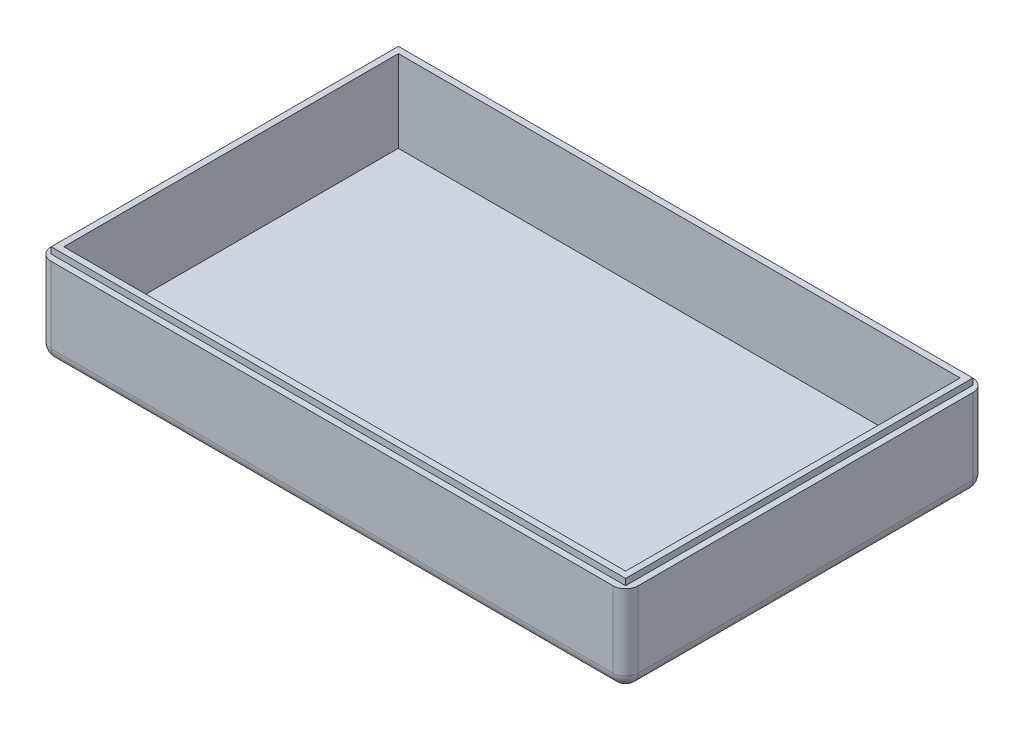
from build123d import *

# Parameters (mm, degrees)
SKETCH1_W           = 93
SKETCH1_H           = 57
BOSS_EXTRUDE1_DEPTH = 14
SHELL1_T            = -2
SKETCH2_W           = 91
SKETCH2_H           = 55
SKETCH2_W_2         = 89
SKETCH2_H_2         = 53
BOSS_EXTRUDE2_DEPTH = 1
FILLET2_R           = 2


with BuildPart() as part:
    # Sketch1 → Boss-Extrude1 (new body)
    with BuildSketch(Plane(origin=(0, 0, 0), x_dir=(1, 0, 0), z_dir=(0, 1, 0))):
        Rectangle(SKETCH1_W, SKETCH1_H)
    extrude(amount=BOSS_EXTRUDE1_DEPTH)

    # Shell1
    shell1_openings = [part.faces().sort_by_distance(p)[0] for p in [
        (0, 14, 0),
    ]]
    offset(amount=SHELL1_T, openings=shell1_openings, kind=Kind.INTERSECTION)

    # Sketch2 → Boss-Extrude2 (add)
    with BuildSketch(Plane(origin=(0, 14, 0), x_dir=(1, 0, 0), z_dir=(0, 1, 0))):
        Rectangle(SKETCH2_W, SKETCH2_H)
        Rectangle(SKETCH2_W_2, SKETCH2_H_2, mode=Mode.SUBTRACT)
    extrude(amount=BOSS_EXTRUDE2_DEPTH)

    # Fillet2
    fillet2_edges = [part.edges().sort_by_distance(p)[0] for p in [
        (0, 0, 28.5),
        (-46.5, 0, 0),
        (0, 0, -28.5),
        (46.5, 0, 0),
        (46.5, 7, 28.5),
        (-46.5, 7, 28.5),
        (-46.5, 7, -28.5),
        (46.5, 7, -28.5),
    ]]
    fillet(fillet2_edges, radius=FILLET2_R)


solid = part.part
